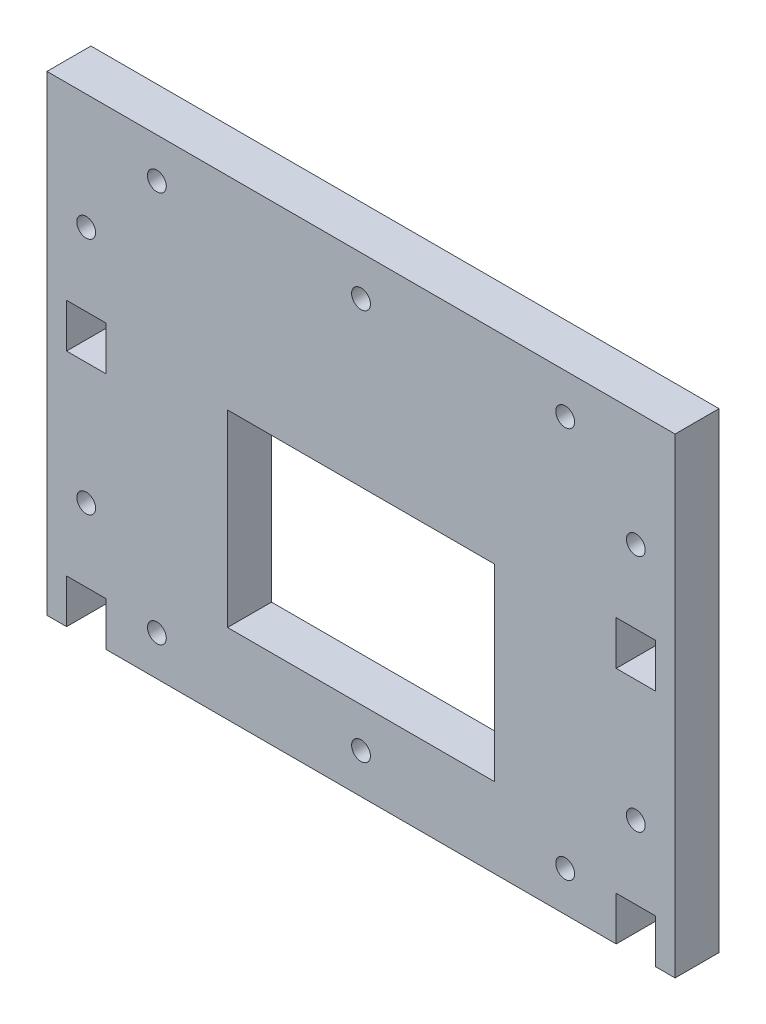
from build123d import *

# Parameters (mm, degrees)
SKETCH1_W                = 200
SKETCH1_H                = 150
BOSS_EXTRUDE1_DEPTH      = 14
SKETCH2_W                = 12.5
SKETCH2_H                = 14
CUT_EXTRUDE1_DEPTH       = 14
F_6_0_6_DIAMETER_HOLE1_D = 6
SKETCH6_W                = 85
SKETCH6_H                = 60
CUT_EXTRUDE2_DEPTH       = 15


with BuildPart() as part:
    # Sketch1 → Boss-Extrude1 (new body)
    with BuildSketch(Plane.XY):
        with Locations((100, 75)):
            Rectangle(SKETCH1_W, SKETCH1_H)
    extrude(amount=BOSS_EXTRUDE1_DEPTH)

    # Sketch2 → Cut-Extrude1 (cut)
    with BuildSketch(Plane(origin=(0, 0, 0), x_dir=(-1, 0, 0), z_dir=(0, 0, -1))):
        with Locations((-12.5, 7)):
            Rectangle(SKETCH2_W, SKETCH2_H)
        with Locations((-187.5, 7)):
            Rectangle(SKETCH2_W, SKETCH2_H)
        with Locations((-12.5, 83)):
            Rectangle(SKETCH2_W, SKETCH2_H)
        with Locations((-187.5, 83)):
            Rectangle(SKETCH2_W, SKETCH2_H)
    extrude(amount=-CUT_EXTRUDE1_DEPTH, mode=Mode.SUBTRACT)

    # Ø6.0 (6) Diameter Hole1 (through all)
    with Locations(Plane.XY.offset(14)):
        with Locations((12.5, 113.265728709), (187.5, 113.265728709), (187.5, 37.265728709), (12.5, 37.265728709), (35, 137.3), (100, 137.3), (165, 137.3), (165, 12.7), (100, 12.7), (35, 12.7)):
            Hole(F_6_0_6_DIAMETER_HOLE1_D / 2)

    # Sketch6 → Cut-Extrude2 (cut, through all)
    with BuildSketch(Plane.XY.offset(14)):
        with Locations((100, 55.4)):
            Rectangle(SKETCH6_W, SKETCH6_H)
    extrude(amount=-CUT_EXTRUDE2_DEPTH, mode=Mode.SUBTRACT)


solid = part.part
